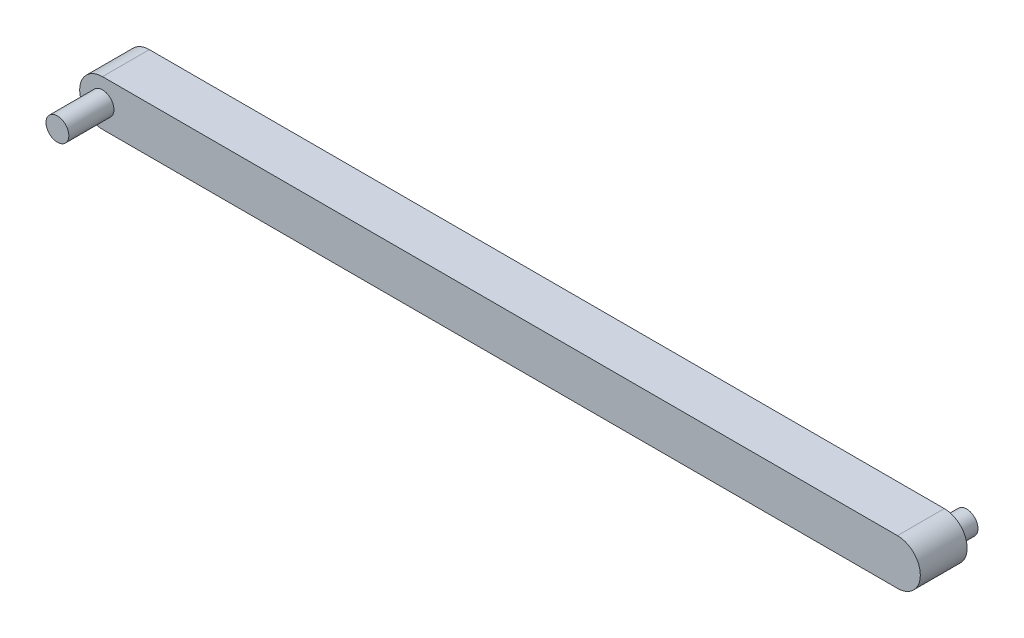
from build123d import *

# Parameters (mm, degrees)
BOSS_EXTRU_1_DEPTH = 5.125
ESQUISSE2_R        = 2.5
BOSS_EXTRU_2_DEPTH = 15
ESQUISSE3_R        = 2.5
BOSS_EXTRU_3_DEPTH = 10


with BuildPart() as part:
    # Esquisse1 → Boss.-Extru.1 (new body, symmetric)
    with BuildSketch(Plane.XY):
        with BuildLine():
            Line((-28.790189362, 6.603053435), (145.209810638, 6.603053435))
            ThreePointArc((145.209810638, 6.603053435), (150.209810638, 1.603053435), (145.209810638, -3.396946565))
            Line((145.209810638, -3.396946565), (-28.790189362, -3.396946565))
            ThreePointArc((-28.790189362, -3.396946565), (-33.790189362, 1.603053435), (-28.790189362, 6.603053435))
        make_face()
    extrude(amount=BOSS_EXTRU_1_DEPTH, both=True)

    # Esquisse2 → Boss.-Extru.2 (add)
    with BuildSketch(Plane.XY):
        with Locations((-28.790189362, 1.603053435)):
            Circle(ESQUISSE2_R)
    extrude(amount=BOSS_EXTRU_2_DEPTH)

    # Esquisse3 → Boss.-Extru.3 (add)
    with BuildSketch(Plane.XY):
        with Locations((145.209810638, 1.603053435)):
            Circle(ESQUISSE3_R)
    extrude(amount=-BOSS_EXTRU_3_DEPTH)


solid = part.part
